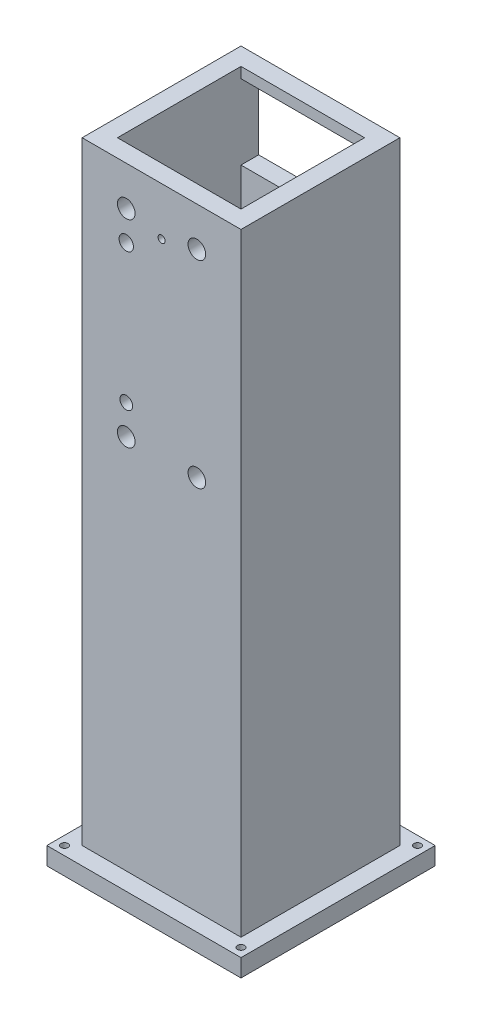
from build123d import *

# Parameters (mm, degrees)
CROQUIS1_W                 = 45
CROQUIS1_H                 = 45
SALIENTE_EXTRUIR1_DEPTH    = 300
CROQUIS4_W                 = 18
CROQUIS4_H                 = 34
CORTAR_EXTRUIR2_DEPTH      = 46
CROQUIS8_W                 = 35
CROQUIS8_H                 = 35
CORTAR_EXTRUIR3_DEPTH      = 301
CROQUIS9_W                 = 35
CROQUIS9_H                 = 21.174410022
CORTAR_EXTRUIR4_DEPTH      = 10
CROQUIS10_R                = 1
CORTAR_EXTRUIR5_DEPTH      = 10
CROQUIS11_W                = 45
CROQUIS11_H                = 26.387879272
CORTAR_EXTRUIR6_DEPTH      = 46
CROQUIS13_W                = 45
CROQUIS13_H                = 100
CORTAR_EXTRUIR7_DEPTH      = 23.5
CORTAR_EXTRUIR7_DEPTH_BACK = 23.5
CROQUIS14_W                = 55
CROQUIS14_H                = 55
SALIENTE_EXTRUIR2_DEPTH    = 5
CROQUIS16_R                = 1
CORTAR_EXTRUIR8_DEPTH      = 1
CORTAR_EXTRUIR8_DEPTH_BACK = 179.612120728
CROQUIS17_R                = 2.5
CROQUIS17_R_2              = 2.03
CROQUIS17_R_3              = 1.793308219
CORTAR_EXTRUIR9_DEPTH      = 6
CORTAR_EXTRUIR9_DEPTH_BACK = 51


with BuildPart() as part:
    # Croquis1 → Saliente-Extruir1 (new body)
    with BuildSketch(Plane(origin=(0, 0, 0), x_dir=(1, 0, 0), z_dir=(0, 1, 0))):
        Rectangle(CROQUIS1_W, CROQUIS1_H)
    extrude(amount=SALIENTE_EXTRUIR1_DEPTH)

    # Croquis4 → Cortar-Extruir2 (cut, through all)
    with BuildSketch(Plane.ZY.offset(22.5)):
        with Locations((13.5, 17)):
            Rectangle(CROQUIS4_W, CROQUIS4_H)
    extrude(amount=-CORTAR_EXTRUIR2_DEPTH, mode=Mode.SUBTRACT)

    # Croquis8 → Cortar-Extruir3 (cut, through all)
    with BuildSketch(Plane(origin=(0, 300, 0), x_dir=(1, 0, 0), z_dir=(0, 1, 0))):
        Rectangle(CROQUIS8_W, CROQUIS8_H)
    extrude(amount=-CORTAR_EXTRUIR3_DEPTH, mode=Mode.SUBTRACT)

    # Croquis9 → Cortar-Extruir4 (cut)
    with BuildSketch(Plane(origin=(0, 0, -22.5), x_dir=(-1, 0, 0), z_dir=(0, 0, -1))):
        with Locations((0, 260)):
            Rectangle(CROQUIS9_W, CROQUIS9_H)
    extrude(amount=-CORTAR_EXTRUIR4_DEPTH, mode=Mode.SUBTRACT)

    # Croquis10 → Cortar-Extruir5 (cut)
    with BuildSketch(Plane.XY.offset(22.5)):
        with Locations((0, 260)):
            Circle(CROQUIS10_R)
    extrude(amount=-CORTAR_EXTRUIR5_DEPTH, mode=Mode.SUBTRACT)

    # Croquis11 → Cortar-Extruir6 (cut, through all)
    with BuildSketch(Plane.XY.offset(22.5)):
        with Locations((0, 286.806060364)):
            Rectangle(CROQUIS11_W, CROQUIS11_H)
    extrude(amount=-CORTAR_EXTRUIR6_DEPTH, mode=Mode.SUBTRACT)

    # Croquis13 → Cortar-Extruir7 (cut, two sides)
    with BuildSketch(Plane(origin=(0, 0, 0), x_dir=(0, 0, -1), z_dir=(1, 0, 0))) as cortar_extruir7_sk:
        with Locations((0, 50)):
            Rectangle(CROQUIS13_W, CROQUIS13_H)
    extrude(amount=CORTAR_EXTRUIR7_DEPTH, mode=Mode.SUBTRACT)
    extrude(cortar_extruir7_sk.sketch, amount=-CORTAR_EXTRUIR7_DEPTH_BACK, mode=Mode.SUBTRACT)

    # Croquis14 → Saliente-Extruir2 (add)
    with BuildSketch(Plane.XZ.offset(-100)):
        Rectangle(CROQUIS14_W, CROQUIS14_H)
    extrude(amount=SALIENTE_EXTRUIR2_DEPTH)

    # Croquis16 → Cortar-Extruir8 (cut, two sides)
    with BuildSketch(Plane.XZ.offset(-95)) as cortar_extruir8_sk:
        with Locations((25, 25)):
            Circle(CROQUIS16_R)
        with Locations((-25, 25)):
            Circle(CROQUIS16_R)
        with Locations((-25, -25)):
            Circle(CROQUIS16_R)
        with Locations((25, -25)):
            Circle(CROQUIS16_R)
    extrude(amount=CORTAR_EXTRUIR8_DEPTH, mode=Mode.SUBTRACT)
    extrude(cortar_extruir8_sk.sketch, amount=-CORTAR_EXTRUIR8_DEPTH_BACK, mode=Mode.SUBTRACT)

    # Croquis17 → Cortar-Extruir9 (cut, two sides)
    with BuildSketch(Plane.XY.offset(22.5)) as cortar_extruir9_sk:
        with Locations((-10, 262.50260741)):
            Circle(CROQUIS17_R)
        with Locations((-10, 254.10260741)):
            Circle(CROQUIS17_R_2)
        with Locations((-10, 214.90260741)):
            Circle(CROQUIS17_R_3)
        with Locations((-10, 206.50260741)):
            Circle(CROQUIS17_R)
        with Locations((10, 262.50260741)):
            Circle(CROQUIS17_R)
        with Locations((10, 206.50260741)):
            Circle(CROQUIS17_R)
    extrude(amount=CORTAR_EXTRUIR9_DEPTH, mode=Mode.SUBTRACT)
    extrude(cortar_extruir9_sk.sketch, amount=-CORTAR_EXTRUIR9_DEPTH_BACK, mode=Mode.SUBTRACT)


solid = part.part
